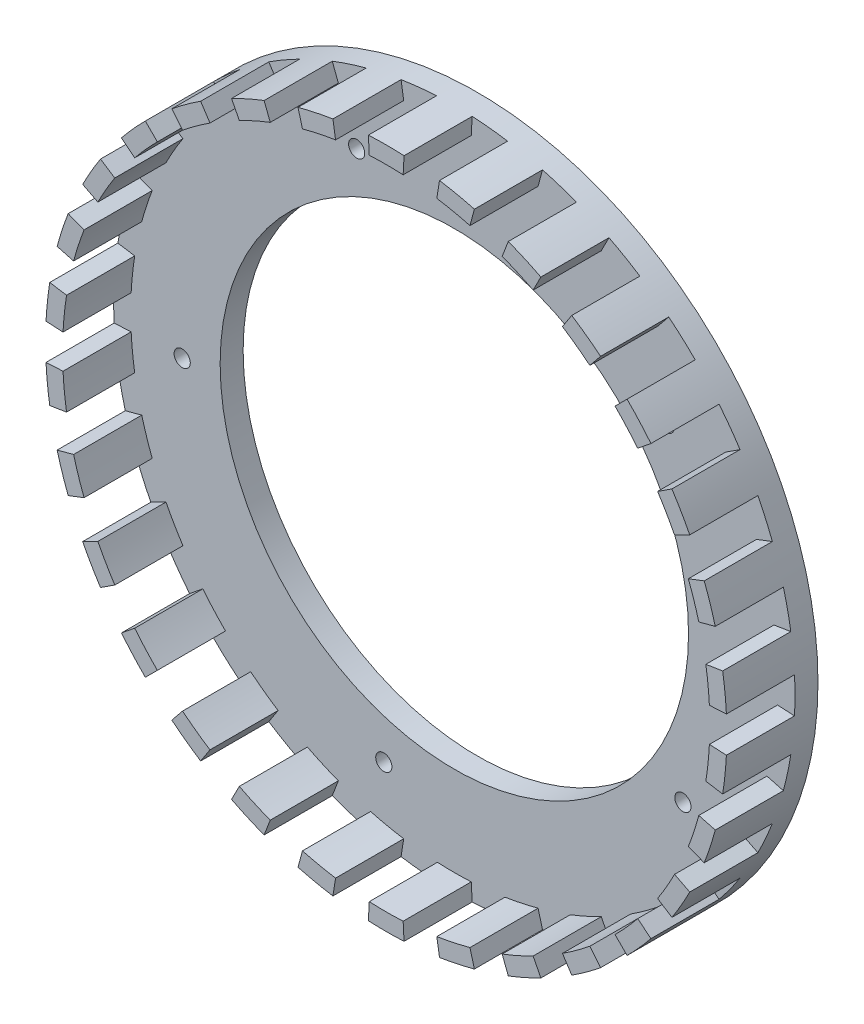
from build123d import *
from build123d.topology import SkipClean

# Parameters (mm, degrees)
SKETCH1_R           = 40
BOSS_EXTRUDE1_DEPTH = 3
SKETCH2_R           = 27.5
CUT_EXTRUDE1_DEPTH  = 57.648036153
MOVE_FACE1_BY       = 0.3
SKETCH6_R           = 0.95
CUT_EXTRUDE8_DEPTH  = 57.632940944
CIRPATTERN3_COUNT   = 5
BOSS_EXTRUDE2_DEPTH = 8
CIRPATTERN4_COUNT   = 30


with BuildPart() as part:
    # Sketch1 → Boss-Extrude1 (new body)
    with BuildSketch(Plane.XY):
        Circle(SKETCH1_R)
    extrude(amount=BOSS_EXTRUDE1_DEPTH)

    # Sketch2 → Cut-Extrude1 (cut, through all)
    with BuildSketch(Plane.XY.offset(3)):
        Circle(SKETCH2_R)
    extrude(amount=-CUT_EXTRUDE1_DEPTH, mode=Mode.SUBTRACT)

    # Move Face1: a face moved inward by 0.3
    extrude(part.faces().sort_by_distance((0, -32, 0))[0], amount=MOVE_FACE1_BY, dir=(0, 0, 1), mode=Mode.SUBTRACT)

    # Sketch6 → Cut-Extrude8 (cut, through all)
    with BuildSketch(Plane(origin=(0, 0, 0.3), x_dir=(-1, 0, 0), z_dir=(0, 0, -1))):
        with Locations((11.467774385, 29.874573648)):
            Circle(SKETCH6_R)
    cut_extrude8 = extrude(amount=-CUT_EXTRUDE8_DEPTH, mode=Mode.SUBTRACT)

    # CirPattern3: Cut-Extrude8 ×5 about axis
    cirpattern3_axis = Axis((0, 0, -88.99), (0, 0, 1))
    for i in range(1, CIRPATTERN3_COUNT):
        add(cut_extrude8.rotate(cirpattern3_axis, i * 360 / CIRPATTERN3_COUNT), mode=Mode.SUBTRACT)

    # Sketch7 → Boss-Extrude2 (add)
    with SkipClean():  # the faces are left unmerged after this step: merging them gives an invalid solid
        with BuildSketch(Plane.XY.offset(3)):
            with BuildLine():
                Line((-1.988766337, 37.947922321), (-2.09343825, 39.94518139))
                ThreePointArc((-2.09343825, 39.94518139), (0, 40), (2.09343825, 39.94518139))
                Line((2.09343825, 39.94518139), (1.988766337, 37.947922321))
                ThreePointArc((1.988766337, 37.947922321), (0, 38), (-1.988766337, 37.947922321))
            make_face()
        boss_extrude2 = extrude(amount=BOSS_EXTRUDE2_DEPTH)

    # CirPattern4: Boss-Extrude2 ×30 about axis
    with SkipClean():  # the faces are left unmerged after this step: merging them gives an invalid solid
        cirpattern4_axis = Axis((0, 0, -88.99), (0, 0, 1))
        for i in range(1, CIRPATTERN4_COUNT):
            add(boss_extrude2.rotate(cirpattern4_axis, i * 360 / CIRPATTERN4_COUNT))


solid = part.part
